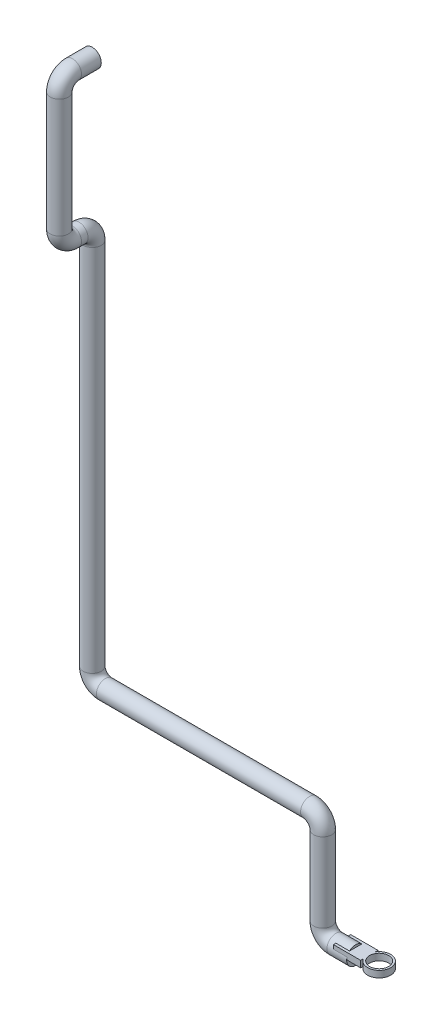
from build123d import *

# Parameters (mm, degrees)
CROQUIS1_R              = 13.7
CROQUIS2_R              = 17.5
CROQUIS2_R_2            = 14.466023188
SALIENTE_EXTRUIR1_DEPTH = 10


with BuildPart() as part:
    # Barrer1: sweep along a curve in space
    with BuildLine() as barrer1_path:
        Line((0, 0, 0), (-30, 0, 0))
        ThreePointArc((-30, 0, 0), (-44.142135624, 5.857864376, 0), (-50, 20, 0))
        Line((-50, 20, 0), (-50, 140, 0))
        ThreePointArc((-50, 140, 0), (-55.857864376, 154.142135624, 0), (-70, 160, 0))
        Line((-70, 160, 0), (-380, 160, 0))
        ThreePointArc((-380, 160, 0), (-394.142135624, 165.857864376, 0), (-400, 180, 0))
        Line((-400, 180, 0), (-400, 740, 0))
        ThreePointArc((-400, 740, 0), (-400, 754.142135624, 5.857864376), (-400, 760, 20))
        Line((-400, 760, 20), (-400, 760, 30))
        ThreePointArc((-400, 760, 30), (-400, 765.857864376, 44.142135624), (-400, 780, 50))
        Line((-400, 780, 50), (-400, 960, 50))
        ThreePointArc((-400, 960, 50), (-400, 974.142135624, 44.142135624), (-400, 980, 30))
        Line((-400, 980, 30), (-400, 980, 0))
    # Croquis1 → Barrer1 (sweep)
    with BuildSketch(Plane(origin=(0, 0, 0), x_dir=(0, 0, -1), z_dir=(1, 0, 0))):
        Circle(CROQUIS1_R)
    sweep(path=barrer1_path.line)

    # Croquis2 → Saliente-Extruir1 (add)
    with BuildSketch(Plane(origin=(0, 0, 0), x_dir=(1, 0, 0), z_dir=(0, 1, 0))):
        with BuildLine():
            Line((20.728883455, -13.13196188), (20.728883455, -9.22916137))
            ThreePointArc((20.728883455, -9.22916137), (18.097393145, 0), (20.728883455, 9.22916137))
            Line((20.728883455, 9.22916137), (20.728883455, 13.13196188))
            Line((20.728883455, 13.13196188), (-20.728883455, 13.13196188))
            Line((-20.728883455, 13.13196188), (-20.728883455, -13.13196188))
            Line((-20.728883455, -13.13196188), (20.728883455, -13.13196188))
        make_face()
        with Locations((35.597393145, 0)):
            Circle(CROQUIS2_R)
        with Locations((35.597393145, 0)):
            Circle(CROQUIS2_R_2, mode=Mode.SUBTRACT)
    extrude(amount=SALIENTE_EXTRUIR1_DEPTH)


solid = part.part
